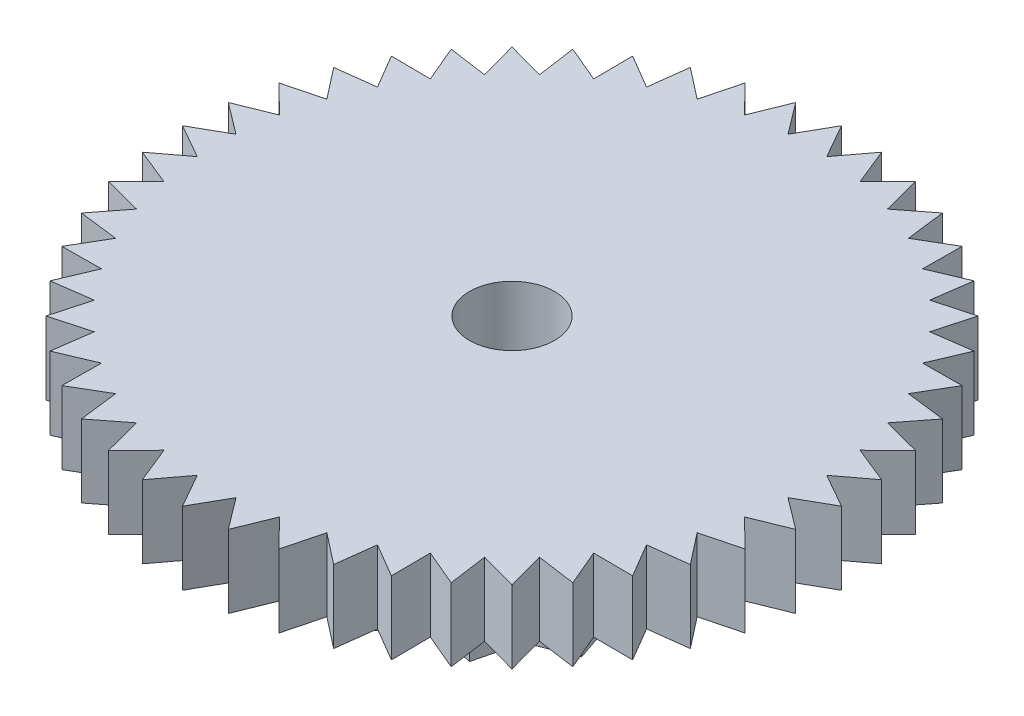
from build123d import *

# Parameters (mm, degrees)
SKETCH2_R          = 0.8
CUT_EXTRUDE1_DEPTH = 4.8
CUT_EXTRUDE2_DEPTH = 4.8
CIRPATTERN1_COUNT  = 48
CUT_EXTRUDE3_DEPTH = 2.43
CIRPATTERN2_COUNT  = 11


with BuildPart() as part:
    # Sketch1 → Revolve1 (revolve)
    with BuildSketch(Plane.XY):
        Polygon((-6.2, 3.8), (-6.2, 2.43), (-2.65, 2.43), (-2.65, 0), (0, 0), (0, 3.8), align=None)
    revolve(axis=Axis((0, 3.8, 0), (0, -1, 0)))

    # Sketch2 → Cut-Extrude1 (cut, through all)
    with BuildSketch(Plane(origin=(0, 3.8, 0), x_dir=(1, 0, 0), z_dir=(0, 1, 0))):
        Circle(SKETCH2_R)
    extrude(amount=-CUT_EXTRUDE1_DEPTH, mode=Mode.SUBTRACT)

    # Sketch3 → Cut-Extrude2 (cut, through all)
    with BuildSketch(Plane(origin=(0, 3.8, 0), x_dir=(1, 0, 0), z_dir=(0, 1, 0))):
        with BuildLine():
            Line((0, 6.2), (0.364241202, 5.557246845))
            Line((0.364241202, 5.557246845), (0.809262392, 6.146958141))
            ThreePointArc((0.809262392, 6.146958141), (0.405499401, 6.186725324), (0, 6.2))
        make_face()
    cut_extrude2 = extrude(amount=-CUT_EXTRUDE2_DEPTH, mode=Mode.SUBTRACT)

    # CirPattern1: Cut-Extrude2 ×48 about axis
    cirpattern1_axis = Axis((0, 0, 0), (0, 1, 0))
    for i in range(1, CIRPATTERN1_COUNT):
        add(cut_extrude2.rotate(cirpattern1_axis, i * 360 / CIRPATTERN1_COUNT), mode=Mode.SUBTRACT)

    # Sketch4 → Cut-Extrude3 (cut)
    with BuildSketch(Plane.XZ):
        with BuildLine():
            Line((0, 2.65), (0.609443257, 2.075573123))
            Line((0.609443257, 2.075573123), (1.432698166, 2.229321862))
            ThreePointArc((1.432698166, 2.229321862), (0.746591276, 2.54265638), (0, 2.65))
        make_face()
    cut_extrude3 = extrude(amount=-CUT_EXTRUDE3_DEPTH, mode=Mode.SUBTRACT)

    # CirPattern2: Cut-Extrude3 ×11 about axis
    cirpattern2_axis = Axis((0, 0, 0), (0, 1, 0))
    for i in range(1, CIRPATTERN2_COUNT):
        add(cut_extrude3.rotate(cirpattern2_axis, i * 360 / CIRPATTERN2_COUNT), mode=Mode.SUBTRACT)


solid = part.part
